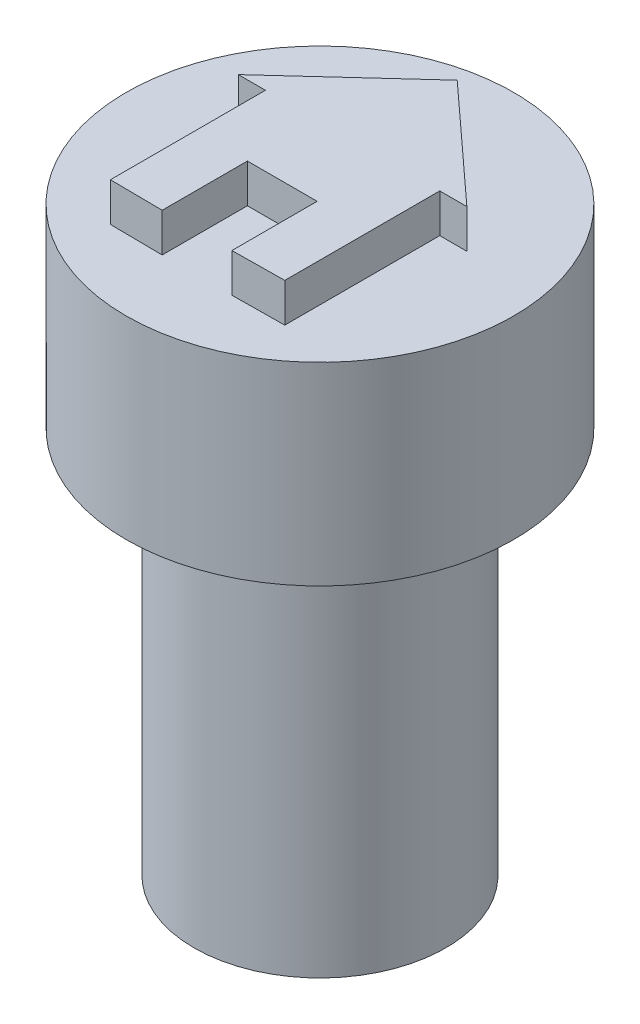
from build123d import *

# Parameters (mm, degrees)
SKETCH1_R           = 3.25
BOSS_EXTRUDE1_DEPTH = 10
SKETCH2_R           = 1.75
CUT_EXTRUDE1_DEPTH  = 2.5
SKETCH6_R           = 5
BOSS_EXTRUDE2_DEPTH = 5
BOSS_EXTRUDE3_DEPTH = 1


with BuildPart() as part:
    # Sketch1 → Boss-Extrude1 (new body)
    with BuildSketch(Plane(origin=(0, 0, 0), x_dir=(1, 0, 0), z_dir=(0, 1, 0))):
        Circle(SKETCH1_R)
    extrude(amount=BOSS_EXTRUDE1_DEPTH)

    # Sketch2 → Cut-Extrude1 (cut)
    with BuildSketch(Plane.XZ):
        Circle(SKETCH2_R)
    extrude(amount=-CUT_EXTRUDE1_DEPTH, mode=Mode.SUBTRACT)

    # Sketch6 → Boss-Extrude2 (add)
    with BuildSketch(Plane(origin=(0, 10, 0), x_dir=(1, 0, 0), z_dir=(0, 1, 0))):
        Circle(SKETCH6_R)
    extrude(amount=BOSS_EXTRUDE2_DEPTH)

    # Sketch12 → Boss-Extrude3 (add)
    with BuildSketch(Plane(origin=(0, 15, 0), x_dir=(1, 0, 0), z_dir=(0, 1, 0))):
        Polygon((0, 3.542487974), (-2.95, 0.842487974), (-2.25, 0.842487974), (-2.25, -3.157512026), (-0.9, -3.172366953), (-0.9, -0.972366953), (0.9, -0.972366953), (0.9, -3.172366953), (2.25, -3.157512026), (2.25, 0.842487974), (2.95, 0.842487974), align=None)
    extrude(amount=BOSS_EXTRUDE3_DEPTH)


solid = part.part
